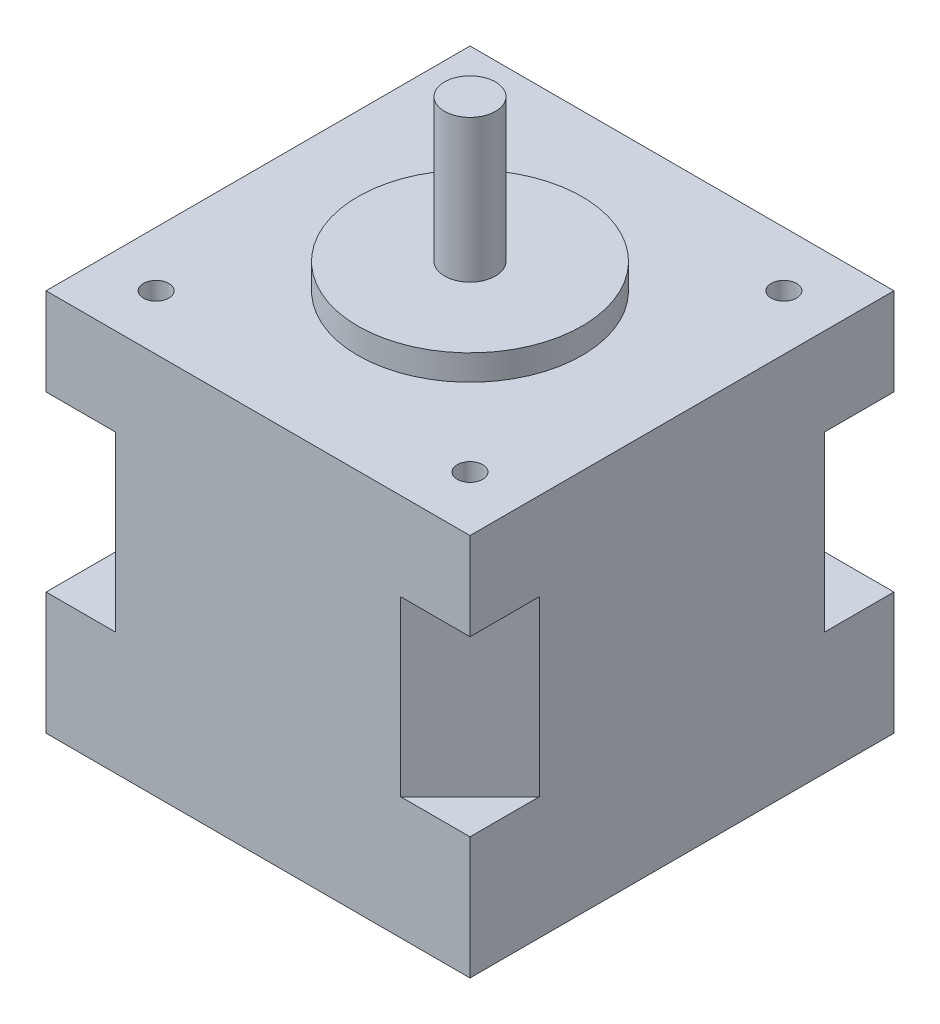
from build123d import *

# Parameters (mm, degrees)
SKETCH1_W               = 41.6
SKETCH1_H               = 41.6
BOSS_EXTRUDE1_DEPTH     = 37.6
SKETCH2_R               = 11
BOSS_EXTRUDE2_DEPTH     = 2.5
SKETCH3_R               = 2.5
BOSS_EXTRUDE3_DEPTH     = 14
SKETCH4_R               = 1.25
CUT_EXTRUDE1_DEPTH      = 8
MIRROR2_COPY_1_SKETCH_R = 1.25
MIRROR2_COPY_1_DEPTH    = 8
CUT_EXTRUDE2_DEPTH      = 17
MIRROR4_COPY_1_DEPTH    = 17
SKETCH10_R              = 4.3
CUT_EXTRUDE3_DEPTH      = 5.7


with BuildPart() as part:
    # Sketch1 → Boss-Extrude1 (new body)
    with BuildSketch(Plane(origin=(0, 0, 0), x_dir=(1, 0, 0), z_dir=(0, 1, 0))):
        Rectangle(SKETCH1_W, SKETCH1_H)
    extrude(amount=BOSS_EXTRUDE1_DEPTH)

    # Sketch2 → Boss-Extrude2 (add)
    with BuildSketch(Plane(origin=(0, 37.6, 0), x_dir=(1, 0, 0), z_dir=(0, 1, 0))):
        Circle(SKETCH2_R)
    extrude(amount=BOSS_EXTRUDE2_DEPTH)

    # Sketch3 → Boss-Extrude3 (add)
    with BuildSketch(Plane(origin=(0, 40.1, 0), x_dir=(1, 0, 0), z_dir=(0, 1, 0))):
        Circle(SKETCH3_R)
    extrude(amount=BOSS_EXTRUDE3_DEPTH)

    # Sketch4 → Cut-Extrude1 (cut)
    with BuildSketch(Plane(origin=(0, 37.6, 0), x_dir=(1, 0, 0), z_dir=(0, 1, 0))):
        with Locations((15.4, 15.4)):
            Circle(SKETCH4_R)
    cut_extrude1 = extrude(amount=-CUT_EXTRUDE1_DEPTH, mode=Mode.SUBTRACT)

    # Mirror1: Cut-Extrude1 across plane
    add(cut_extrude1.mirror(Plane(origin=(0, 0, 0), x_dir=(0, 0, 1), z_dir=(1, 0, 0))), mode=Mode.SUBTRACT)

    # Mirror2: Cut-Extrude1 across plane
    add(cut_extrude1.mirror(Plane.XY), mode=Mode.SUBTRACT)

    # Mirror2 copy 1 sketch → Mirror2 copy 1 (cut)
    with BuildSketch(Plane(origin=(0, 37.6, 0), x_dir=(-1, 0, 0), z_dir=(0, 1, 0))):
        with Locations((15.4, 15.4)):
            Circle(MIRROR2_COPY_1_SKETCH_R)
    extrude(amount=-MIRROR2_COPY_1_DEPTH, mode=Mode.SUBTRACT)

    # Sketch9 → Cut-Extrude2 (cut)
    with BuildSketch(Plane(origin=(0, 12, 0), x_dir=(1, 0, 0), z_dir=(0, 1, 0))):
        Polygon((20.8, 14), (14, 20.8), (20.8, 20.8), align=None)
    cut_extrude2 = extrude(amount=CUT_EXTRUDE2_DEPTH, mode=Mode.SUBTRACT)

    # Mirror3: Cut-Extrude2 across plane
    add(cut_extrude2.mirror(Plane.XY), mode=Mode.SUBTRACT)

    # Mirror4: Cut-Extrude2 across plane
    add(cut_extrude2.mirror(Plane(origin=(0, 0, 0), x_dir=(0, 0, 1), z_dir=(1, 0, 0))), mode=Mode.SUBTRACT)

    # Mirror4 copy 1 sketch → Mirror4 copy 1 (cut)
    with BuildSketch(Plane(origin=(0, 12, 0), x_dir=(-1, 0, 0), z_dir=(0, 1, 0))):
        Polygon((20.8, 14), (14, 20.8), (20.8, 20.8), align=None)
    extrude(amount=MIRROR4_COPY_1_DEPTH, mode=Mode.SUBTRACT)

    # Sketch10 → Cut-Extrude3 (cut)
    with BuildSketch(Plane.XZ):
        Circle(SKETCH10_R)
    extrude(amount=-CUT_EXTRUDE3_DEPTH, mode=Mode.SUBTRACT)


solid = part.part
